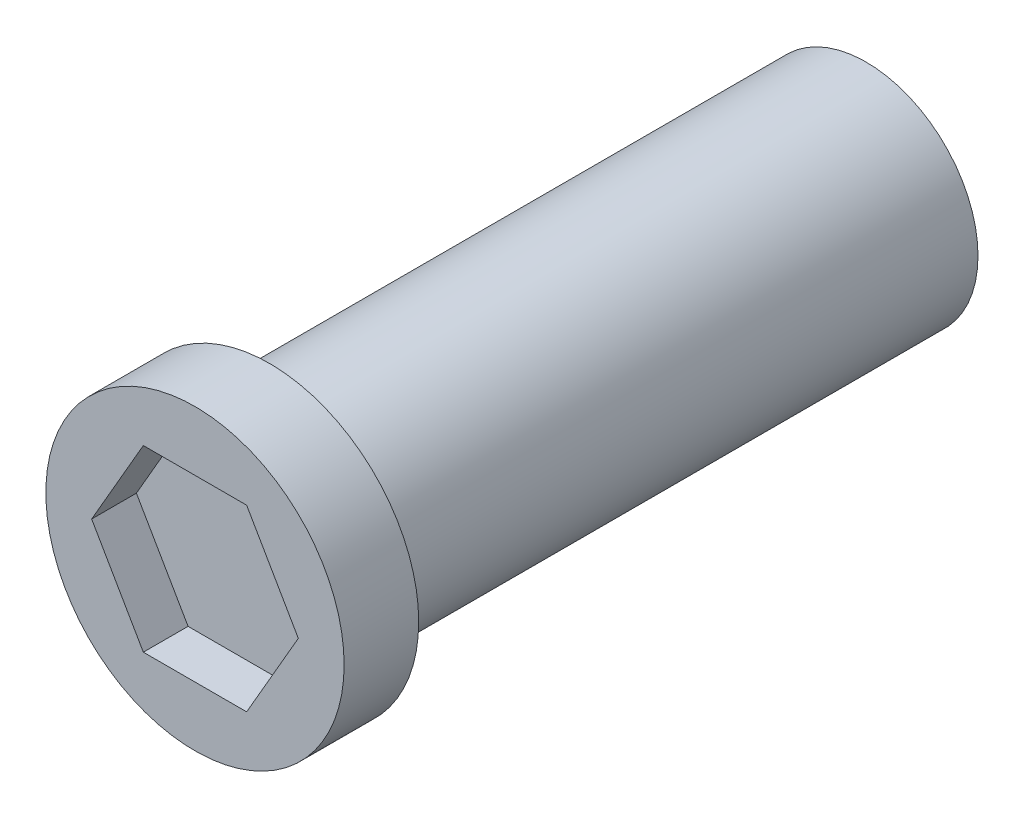
from build123d import *

# Parameters (mm, degrees)
SKETCH1_R           = 7.5
BOSS_EXTRUDE1_DEPTH = 40
SKETCH2_R           = 10
BOSS_EXTRUDE2_DEPTH = 5
CUT_EXTRUDE1_DEPTH  = 3


with BuildPart() as part:
    # Sketch1 → Boss-Extrude1 (new body)
    with BuildSketch(Plane.XY):
        Circle(SKETCH1_R)
    extrude(amount=BOSS_EXTRUDE1_DEPTH)

    # Sketch2 → Boss-Extrude2 (add)
    with BuildSketch(Plane.XY.offset(40)):
        Circle(SKETCH2_R)
    extrude(amount=BOSS_EXTRUDE2_DEPTH)

    # Sketch3 → Cut-Extrude1 (cut)
    with BuildSketch(Plane.XY.offset(45)):
        Polygon((-6.92820323, 0), (-3.464101615, -6), (3.464101615, -6), (6.92820323, 0), (3.464101615, 6), (-3.464101615, 6), align=None)
    extrude(amount=-CUT_EXTRUDE1_DEPTH, mode=Mode.SUBTRACT)


solid = part.part
